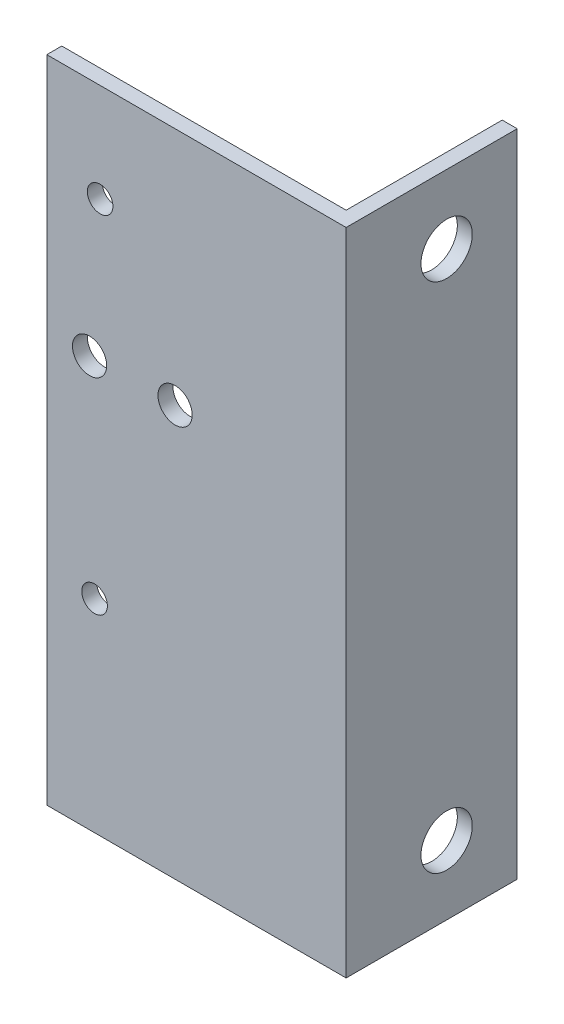
from build123d import *

# Parameters (mm, degrees)
BOSS_EXTRUDE1_DEPTH = 76
CUT_EXTRUDE1_REACH  = 3.75
SKETCH3_R           = 3
CUT_EXTRUDE2_REACH  = 22
SKETCH4_R           = 1.5
SKETCH4_R_2         = 2


with BuildPart() as part:
    # Sketch1 → Boss-Extrude1 (new body)
    with BuildSketch(Plane(origin=(0, 0, 0), x_dir=(1, 0, 0), z_dir=(0, 1, 0))):
        Polygon((-35, 0), (-35, -1.75), (0, -1.75), (0, 18.25), (-1.75, 18.25), (-1.75, 0), align=None)
    extrude(amount=BOSS_EXTRUDE1_DEPTH)

    # Sketch3 → Cut-Extrude1 (cut, up to next)
    with BuildSketch(Plane.ZY.offset(1.75), mode=Mode.PRIVATE) as cut_extrude1_sk1:
        with Locations((-10, 8.05)):
            Circle(SKETCH3_R)
    cut_extrude1_tool1 = extrude(cut_extrude1_sk1.sketch, amount=-CUT_EXTRUDE1_REACH, mode=Mode.PRIVATE) & part.part
    add(cut_extrude1_tool1.solids().sort_by_distance((-1.75, 8.05, -10))[0], mode=Mode.SUBTRACT)
    # Sketch3 → Cut-Extrude1 (cut, up to next)
    with BuildSketch(Plane.ZY.offset(1.75), mode=Mode.PRIVATE) as cut_extrude1_sk2:
        with Locations((-10, 67.955)):
            Circle(SKETCH3_R)
    cut_extrude1_tool2 = extrude(cut_extrude1_sk2.sketch, amount=-CUT_EXTRUDE1_REACH, mode=Mode.PRIVATE) & part.part
    add(cut_extrude1_tool2.solids().sort_by_distance((-1.75, 67.955, -10))[0], mode=Mode.SUBTRACT)

    # Sketch4 → Cut-Extrude2 (cut, up to next)
    with BuildSketch(Plane.XY.offset(1.75), mode=Mode.PRIVATE) as cut_extrude2_sk1:
        with Locations((-28.76701924, 64.5)):
            Circle(SKETCH4_R)
    cut_extrude2_tool1 = extrude(cut_extrude2_sk1.sketch, amount=-CUT_EXTRUDE2_REACH, mode=Mode.PRIVATE) & part.part
    add(cut_extrude2_tool1.solids().sort_by_distance((-28.767019, 64.5, 1.75))[0], mode=Mode.SUBTRACT)
    # Sketch4 → Cut-Extrude2 (cut, up to next)
    with BuildSketch(Plane.XY.offset(1.75), mode=Mode.PRIVATE) as cut_extrude2_sk2:
        with Locations((-29.41701924, 23.7)):
            Circle(SKETCH4_R)
    cut_extrude2_tool2 = extrude(cut_extrude2_sk2.sketch, amount=-CUT_EXTRUDE2_REACH, mode=Mode.PRIVATE) & part.part
    add(cut_extrude2_tool2.solids().sort_by_distance((-29.417019, 23.7, 1.75))[0], mode=Mode.SUBTRACT)
    # Sketch4 → Cut-Extrude2 (cut, up to next)
    with BuildSketch(Plane.XY.offset(1.75), mode=Mode.PRIVATE) as cut_extrude2_sk3:
        with Locations((-30, 48)):
            Circle(SKETCH4_R_2)
    cut_extrude2_tool3 = extrude(cut_extrude2_sk3.sketch, amount=-CUT_EXTRUDE2_REACH, mode=Mode.PRIVATE) & part.part
    add(cut_extrude2_tool3.solids().sort_by_distance((-30, 48, 1.75))[0], mode=Mode.SUBTRACT)
    # Sketch4 → Cut-Extrude2 (cut, up to next)
    with BuildSketch(Plane.XY.offset(1.75), mode=Mode.PRIVATE) as cut_extrude2_sk4:
        with Locations((-20, 48)):
            Circle(SKETCH4_R_2)
    cut_extrude2_tool4 = extrude(cut_extrude2_sk4.sketch, amount=-CUT_EXTRUDE2_REACH, mode=Mode.PRIVATE) & part.part
    add(cut_extrude2_tool4.solids().sort_by_distance((-20, 48, 1.75))[0], mode=Mode.SUBTRACT)


solid = part.part
